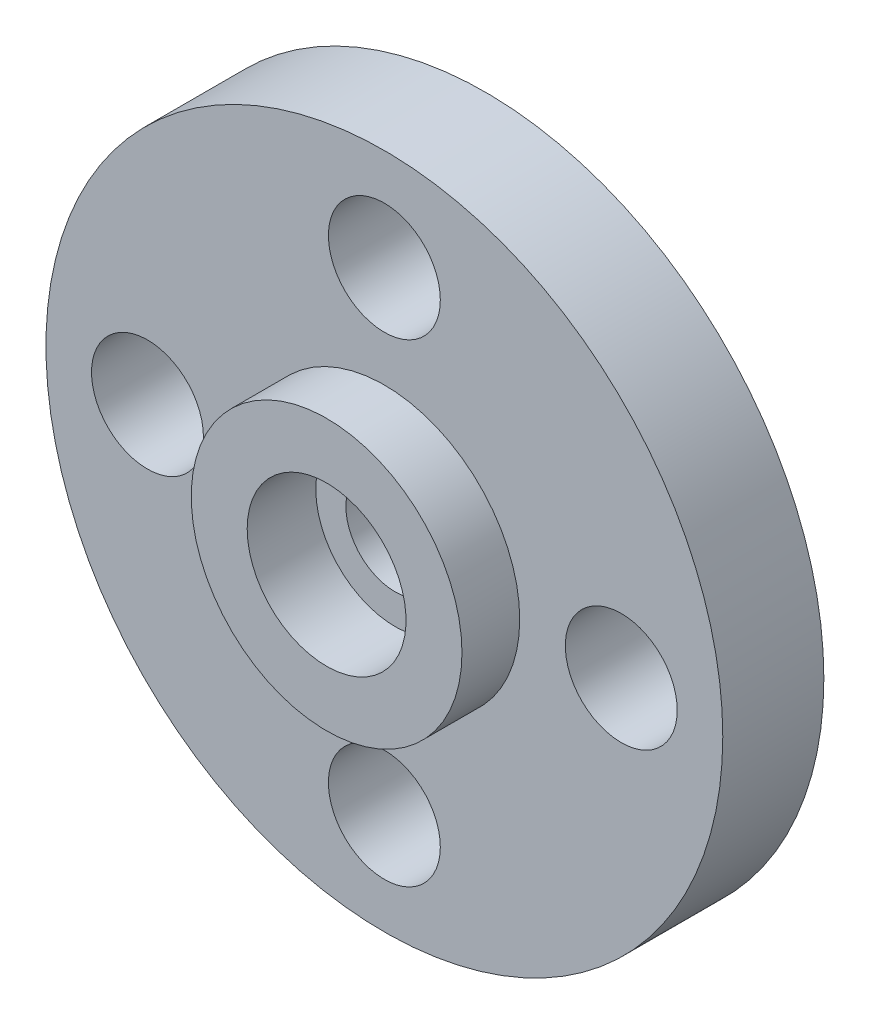
from build123d import *

# Parameters (mm, degrees)
SKETCH1_R         = 17.526
EXTRUDE1_DEPTH    = 6.35
EXTRUDE2_START    = 6.35
SKETCH1_3_R       = 47.625
EXTRUDE2_DEPTH    = 14.224
EXTRUDE3_START    = 20.574
SKETCH1_4_R       = 19.05
EXTRUDE3_DEPTH    = 8.128
EXTRUDE4_START    = 6.35
SKETCH1_5_R       = 7.874
EXTRUDE4_DEPTH    = 14.224
CIRPATTERN1_COUNT = 4
SKETCH3_R         = 11.176
EXTRUDE5_DEPTH    = 9.652
EXTRUDE6_REACH    = 30.702
SKETCH3_3_R       = 6.9342


with BuildPart() as part:
    # Sketch1 → Extrude1 (new body)
    with BuildSketch(Plane.XY):
        Circle(SKETCH1_R)
    extrude(amount=EXTRUDE1_DEPTH)

    # Sketch1_3 → Extrude2 (add)
    with BuildSketch(Plane.XY.offset(EXTRUDE2_START)):
        Circle(SKETCH1_3_R)
    extrude(amount=EXTRUDE2_DEPTH)

    # Sketch1_4 → Extrude3 (add)
    with BuildSketch(Plane.XY.offset(EXTRUDE3_START)):
        Circle(SKETCH1_4_R)
    extrude(amount=EXTRUDE3_DEPTH)

    # Sketch1_5 → Extrude4 (cut)
    with BuildSketch(Plane.XY.offset(EXTRUDE4_START)):
        with Locations((0, 33.3375)):
            Circle(SKETCH1_5_R)
    extrude4 = extrude(amount=EXTRUDE4_DEPTH, mode=Mode.SUBTRACT)

    # CirPattern1: Extrude4 ×4 about axis
    cirpattern1_axis = Axis((0, 0, 0), (0, 0, 1))
    for i in range(1, CIRPATTERN1_COUNT):
        add(extrude4.rotate(cirpattern1_axis, i * 360 / CIRPATTERN1_COUNT), mode=Mode.SUBTRACT)

    # Sketch3 → Extrude5 (cut)
    with BuildSketch(Plane(origin=(0, 0, 28.702), x_dir=(-1, 0, 0), z_dir=(0, 0, -1))):
        Circle(SKETCH3_R)
    extrude(amount=EXTRUDE5_DEPTH, mode=Mode.SUBTRACT)

    # Sketch3_3 → Extrude6 (cut, up to next)
    with BuildSketch(Plane(origin=(0, 0, 28.702), x_dir=(-1, 0, 0), z_dir=(0, 0, -1)), mode=Mode.PRIVATE) as extrude6_sk1:
        Circle(SKETCH3_3_R)
    extrude6_tool1 = extrude(extrude6_sk1.sketch, amount=EXTRUDE6_REACH, mode=Mode.PRIVATE) & part.part
    add(extrude6_tool1.solids().sort_by_distance((0, 0, 28.702))[0], mode=Mode.SUBTRACT)


solid = part.part
